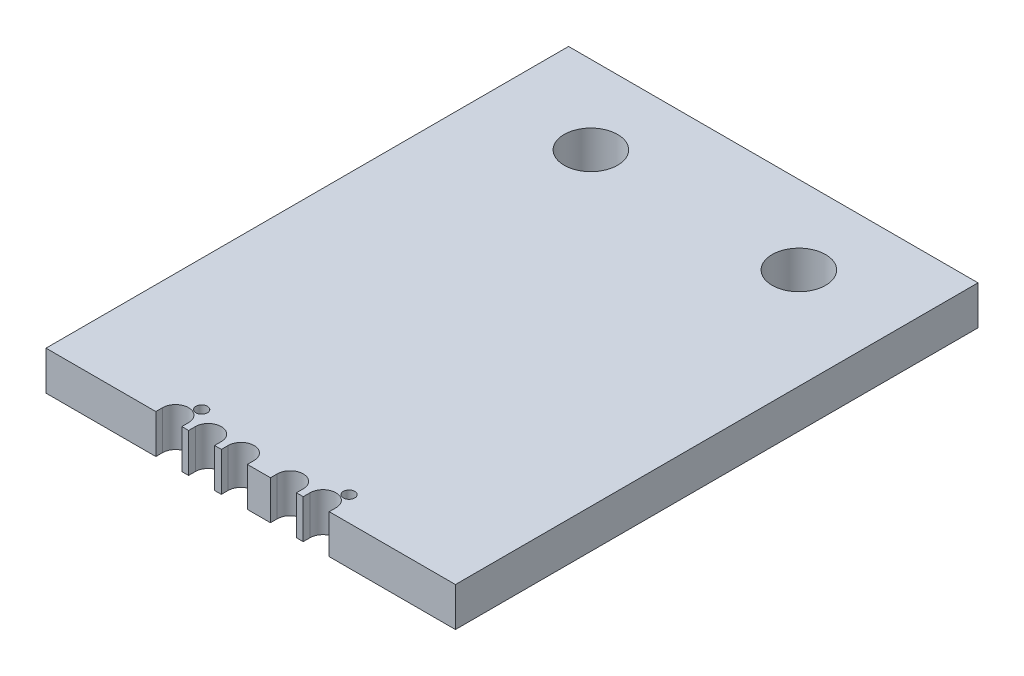
from build123d import *

# Parameters (mm, degrees)
SKETCH1_R           = 0.7
SKETCH1_R_2         = 3.2639
BOSS_EXTRUDE1_DEPTH = 4.7625


with BuildPart() as part:
    # Sketch1 → Boss-Extrude1 (new body)
    with BuildSketch(Plane(origin=(0, 0, 0), x_dir=(1, 0, 0), z_dir=(0, 1, 0))):
        with BuildLine():
            Line((16, 1.185131266), (16, 65))
            Line((16, 65), (66, 65))
            Line((66, 65), (66, 1.185131266))
            Line((66, 1.185131266), (50.5875, 1.185131266))
            Line((50.5875, 1.185131266), (50.5875, 2.009827459))
            ThreePointArc((50.5875, 2.009827459), (49, 3.597327459), (47.4125, 2.009827459))
            Line((47.4125, 2.009827459), (47.4125, 1.185131266))
            Line((47.4125, 1.185131266), (46.5875, 1.185131266))
            Line((46.5875, 1.185131266), (46.5875, 2.009827459))
            ThreePointArc((46.5875, 2.009827459), (45, 3.597327459), (43.4125, 2.009827459))
            Line((43.4125, 2.009827459), (43.4125, 1.185131266))
            Line((43.4125, 1.185131266), (40.5875, 1.185131266))
            Line((40.5875, 1.185131266), (40.5875, 2.009827459))
            ThreePointArc((40.5875, 2.009827459), (39, 3.597327459), (37.4125, 2.009827459))
            Line((37.4125, 2.009827459), (37.4125, 1.185131266))
            Line((37.4125, 1.185131266), (36.5875, 1.185131266))
            Line((36.5875, 1.185131266), (36.5875, 2.009827459))
            ThreePointArc((36.5875, 2.009827459), (35, 3.597327459), (33.4125, 2.009827459))
            Line((33.4125, 2.009827459), (33.4125, 1.185131266))
            Line((33.4125, 1.185131266), (32.5875, 1.185131266))
            Line((32.5875, 1.185131266), (32.5875, 2.009827459))
            ThreePointArc((32.5875, 2.009827459), (31, 3.597327459), (29.4125, 2.009827459))
            Line((29.4125, 2.009827459), (29.4125, 1.185131266))
            Line((29.4125, 1.185131266), (16, 1.185131266))
        make_face()
        with Locations((32, 4.197327459)):
            Circle(SKETCH1_R, mode=Mode.SUBTRACT)
        with Locations((53.7, 55.426122104)):
            Circle(SKETCH1_R_2, mode=Mode.SUBTRACT)
        with Locations((28.3, 55.426122104)):
            Circle(SKETCH1_R_2, mode=Mode.SUBTRACT)
        with Locations((50, 4.197327459)):
            Circle(SKETCH1_R, mode=Mode.SUBTRACT)
    extrude(amount=-BOSS_EXTRUDE1_DEPTH)


solid = part.part
